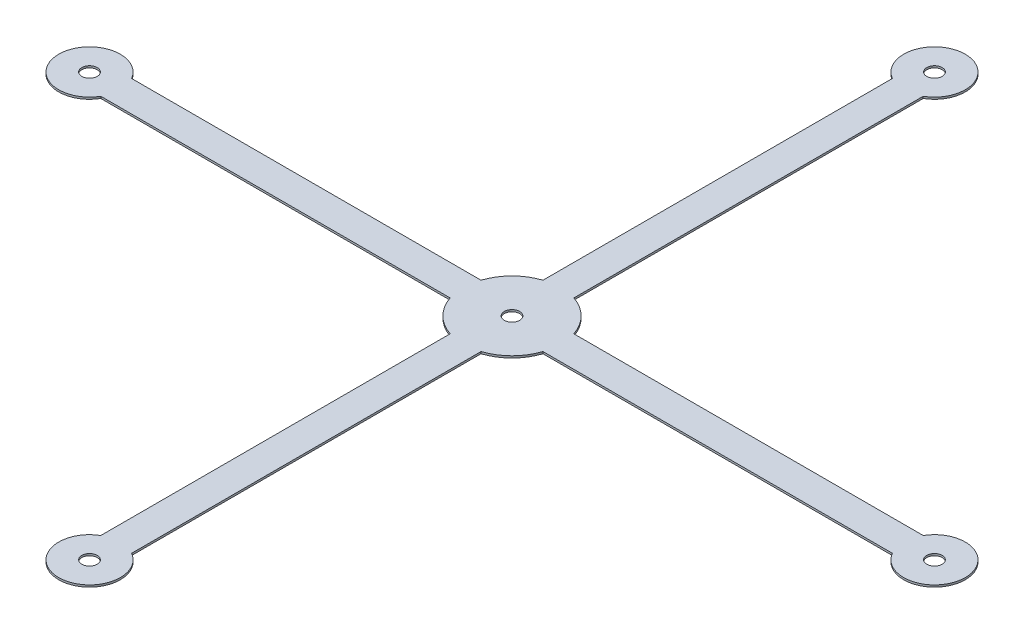
from build123d import *

# Parameters (mm, degrees)
SKETCH1_R           = 1
BOSS_EXTRUDE1_DEPTH = 0.254
SKETCH2_R           = 1
CUT_EXTRUDE1_DEPTH  = 10


with BuildPart() as part:
    # Sketch1 → Boss-Extrude1 (new body)
    with BuildSketch(Plane(origin=(0, 0, 0), x_dir=(1, 0, 0), z_dir=(0, 1, 0))):
        with BuildLine():
            Line((-54.864, 4), (-4.931784667, 4))
            ThreePointArc((-4.931784667, 4), (-4.490128061, 4.490128061), (-4, 4.931784667))
            Line((-4, 4.931784667), (-4, 54.864))
            ThreePointArc((-4, 54.864), (0, 58.864), (4, 54.864))
            Line((4, 54.864), (4, 4.931784667))
            ThreePointArc((4, 4.931784667), (4.490128061, 4.490128061), (4.931784667, 4))
            Line((4.931784667, 4), (54.864, 4))
            ThreePointArc((54.864, 4), (58.864, 0), (54.864, -4))
            Line((54.864, -4), (4.931784667, -4))
            ThreePointArc((4.931784667, -4), (4.490128061, -4.490128061), (4, -4.931784667))
            Line((4, -4.931784667), (4, -54.864))
            ThreePointArc((4, -54.864), (0, -58.864), (-4, -54.864))
            Line((-4, -54.864), (-4, -4.931784667))
            ThreePointArc((-4, -4.931784667), (-4.490128061, -4.490128061), (-4.931784667, -4))
            Line((-4.931784667, -4), (-54.864, -4))
            ThreePointArc((-54.864, -4), (-58.864, 0), (-54.864, 4))
        make_face()
        with Locations((-54.864, 0)):
            Circle(SKETCH1_R, mode=Mode.SUBTRACT)
        with Locations((0, 54.864)):
            Circle(SKETCH1_R, mode=Mode.SUBTRACT)
        with Locations((54.864, 0)):
            Circle(SKETCH1_R, mode=Mode.SUBTRACT)
        with Locations((0, -54.864)):
            Circle(SKETCH1_R, mode=Mode.SUBTRACT)
    extrude(amount=BOSS_EXTRUDE1_DEPTH)

    # Sketch2 → Cut-Extrude1 (cut)
    with BuildSketch(Plane(origin=(0, 0.254, 0), x_dir=(1, 0, 0), z_dir=(0, 1, 0))):
        Circle(SKETCH2_R)
        with BuildLine():
            Line((-2, -51.399898385), (-2, -6.026815079))
            ThreePointArc((-2, -6.026815079), (-3.049552902, -5.569804943), (-4, -4.931784667))
            Line((-4, -4.931784667), (-4, -54.864))
            ThreePointArc((-4, -54.864), (-3.464101615, -52.864), (-2, -51.399898385))
        make_face()
        with BuildLine():
            Line((2, -51.399898385), (2, -6.026815079))
            ThreePointArc((2, -6.026815079), (3.049552902, -5.569804943), (4, -4.931784667))
            Line((4, -4.931784667), (4, -54.864))
            ThreePointArc((4, -54.864), (3.464101615, -52.864), (2, -51.399898385))
        make_face()
        with BuildLine():
            Line((-54.864, 4), (-4.931784667, 4))
            ThreePointArc((-4.931784667, 4), (-5.569804943, 3.049552902), (-6.026815079, 2))
            Line((-6.026815079, 2), (-51.399898385, 2))
            ThreePointArc((-51.399898385, 2), (-52.864, 3.464101615), (-54.864, 4))
        make_face()
        with BuildLine():
            Line((-51.399898385, -2), (-6.026815079, -2))
            ThreePointArc((-6.026815079, -2), (-5.569804943, -3.049552902), (-4.931784667, -4))
            Line((-4.931784667, -4), (-54.864, -4))
            ThreePointArc((-54.864, -4), (-52.864, -3.464101615), (-51.399898385, -2))
        make_face()
        with BuildLine():
            Line((4, 54.864), (4, 4.931784667))
            ThreePointArc((4, 4.931784667), (3.049552902, 5.569804943), (2, 6.026815079))
            Line((2, 6.026815079), (2, 51.399898385))
            ThreePointArc((2, 51.399898385), (3.464101615, 52.864), (4, 54.864))
        make_face()
        with BuildLine():
            Line((-2, 51.399898385), (-2, 6.026815079))
            ThreePointArc((-2, 6.026815079), (-3.049552902, 5.569804943), (-4, 4.931784667))
            Line((-4, 4.931784667), (-4, 54.864))
            ThreePointArc((-4, 54.864), (-3.464101615, 52.864), (-2, 51.399898385))
        make_face()
        with BuildLine():
            Line((54.864, -4), (4.931784667, -4))
            ThreePointArc((4.931784667, -4), (5.569804943, -3.049552902), (6.026815079, -2))
            Line((6.026815079, -2), (51.399898385, -2))
            ThreePointArc((51.399898385, -2), (52.864, -3.464101615), (54.864, -4))
        make_face()
        with BuildLine():
            Line((51.399898385, 2), (6.026815079, 2))
            ThreePointArc((6.026815079, 2), (5.569804943, 3.049552902), (4.931784667, 4))
            Line((4.931784667, 4), (54.864, 4))
            ThreePointArc((54.864, 4), (52.864, 3.464101615), (51.399898385, 2))
        make_face()
    extrude(amount=-CUT_EXTRUDE1_DEPTH, mode=Mode.SUBTRACT)


solid = part.part
